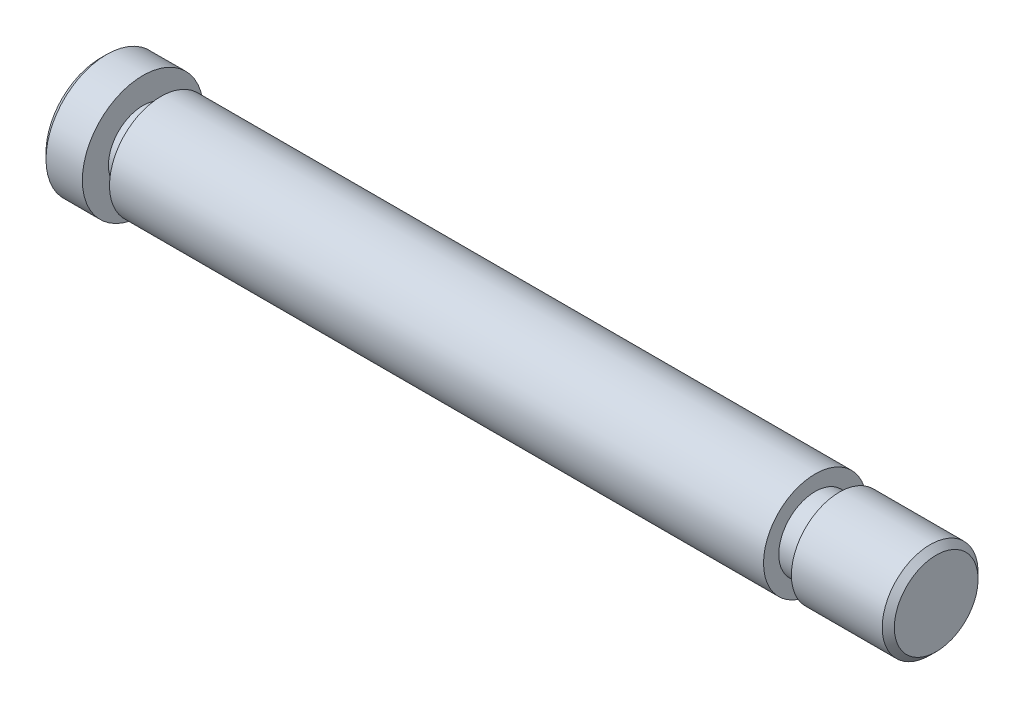
from build123d import *

# Parameters (mm, degrees)
CHAMFER1_SIZE = 0.5
CHAMFER2_SIZE = 0.5


with BuildPart() as part:
    # Sketch1 → Revolve1 (revolve)
    with BuildSketch(Plane.XY):
        Polygon((-8.523357549, 1.5), (-8.523357549, 5), (-5.023357549, 5), (-5.023357549, 2.846083032), (-3.523357549, 2.846083032), (-3.523357549, 4.257689054), (50.476642451, 4.257689054), (50.476642451, 3), (52.476642451, 3), (52.476642451, 3.956427418), (60.476642451, 3.956427418), (60.476642451, 0), (16.976642451, 0), (16.976642451, 1.5), align=None)
    revolve(axis=Axis((-14.970386809, 0, 0), (1, 0, 0)))

    # Chamfer1
    chamfer1_edges = [part.edges().sort_by_distance(p)[0] for p in [
        (-8.523357549, -5, 0),
    ]]
    chamfer(chamfer1_edges, length=CHAMFER1_SIZE)

    # Chamfer2
    chamfer2_edges = [part.edges().sort_by_distance(p)[0] for p in [
        (60.476642451, -3.956427418, 0),
    ]]
    chamfer(chamfer2_edges, length=CHAMFER2_SIZE)


solid = part.part
